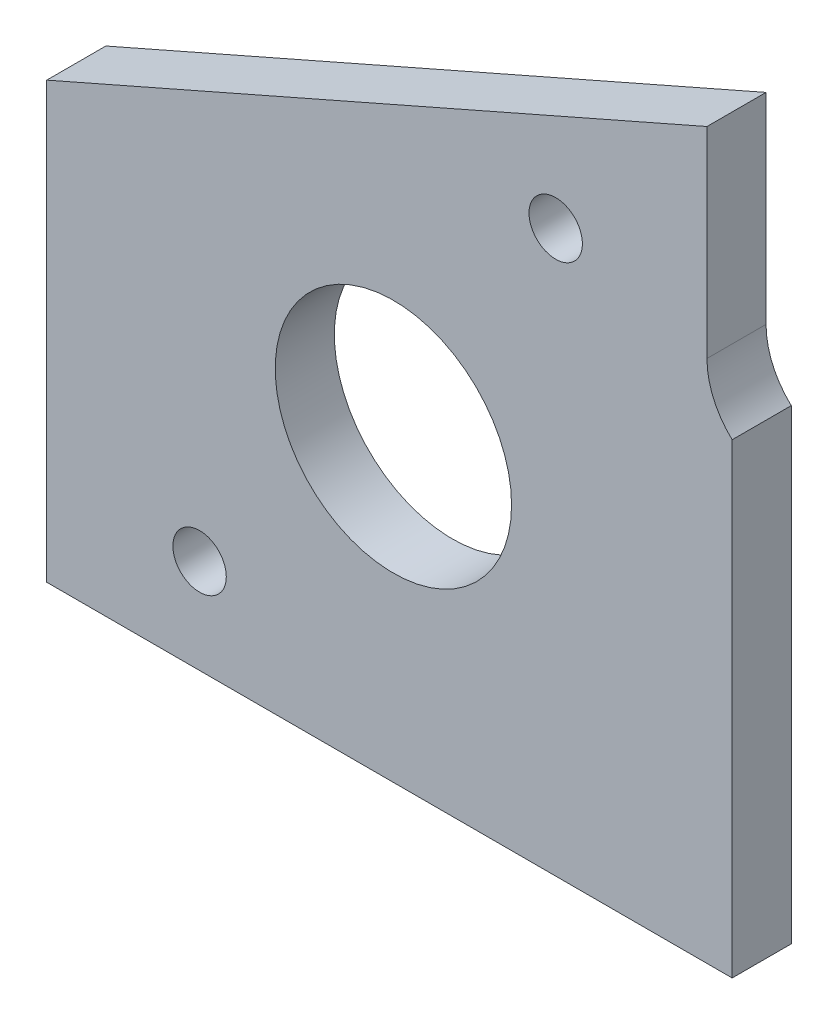
from build123d import *

# Parameters (mm, degrees)
BOSS_EXTRUDE1_DEPTH         = 4.7625
F_3_4_0_75_DIAMETER_HOLE1_D = 19.05
F_6_CLEARANCE_HOLE1_D       = 4.3053


with BuildPart() as part:
    # Sketch1 → Boss-Extrude1 (new body)
    with BuildSketch(Plane.XY):
        with BuildLine():
            Line((-13.97, 22.86), (-13.97, 60.431603094))
            ThreePointArc((-13.97, 60.431603094), (-15.471871133, 62.5475), (-16.002, 65.0875))
            Line((-16.002, 65.0875), (-16.002, 81.28))
            Line((-16.002, 81.28), (-69.215, 57.912))
            Line((-69.215, 57.912), (-69.215, 22.86))
            Line((-69.215, 22.86), (-13.97, 22.86))
        make_face()
    extrude(amount=BOSS_EXTRUDE1_DEPTH)

    # 3/4 (0.75) Diameter Hole1 (through all)
    with Locations(Plane.XY.offset(4.7625)):
        with Locations((-41.275, 46.99)):
            Hole(F_3_4_0_75_DIAMETER_HOLE1_D / 2)

    # #6 Clearance Hole1 (through all)
    with Locations(Plane.XY.offset(4.7625)):
        with Locations((-56.896, 30.48), (-28.194, 68.072)):
            Hole(F_6_CLEARANCE_HOLE1_D / 2)


solid = part.part
